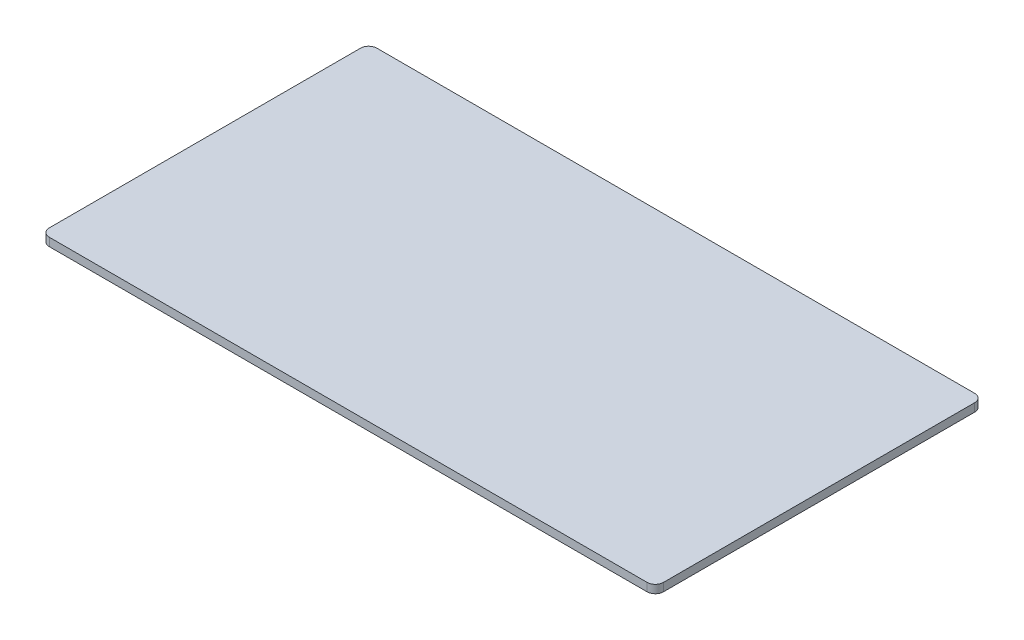
from build123d import *

# Parameters (mm, degrees)
SKETCH2_W           = 1500
SKETCH2_H           = 800
BOSS_EXTRUDE1_DEPTH = 10
FILLET1_R           = 20


with BuildPart() as part:
    # Sketch2 → Boss-Extrude1 (new body, symmetric)
    with BuildSketch(Plane(origin=(0, 0, 0), x_dir=(1, 0, 0), z_dir=(0, 1, 0))):
        Rectangle(SKETCH2_W, SKETCH2_H)
    extrude(amount=BOSS_EXTRUDE1_DEPTH, both=True)

    # Fillet1
    fillet1_edges = [part.edges().sort_by_distance(p)[0] for p in [
        (750, 0, 400),
        (-750, 0, 400),
        (-750, 0, -400),
        (750, 0, -400),
    ]]
    fillet(fillet1_edges, radius=FILLET1_R)


solid = part.part
